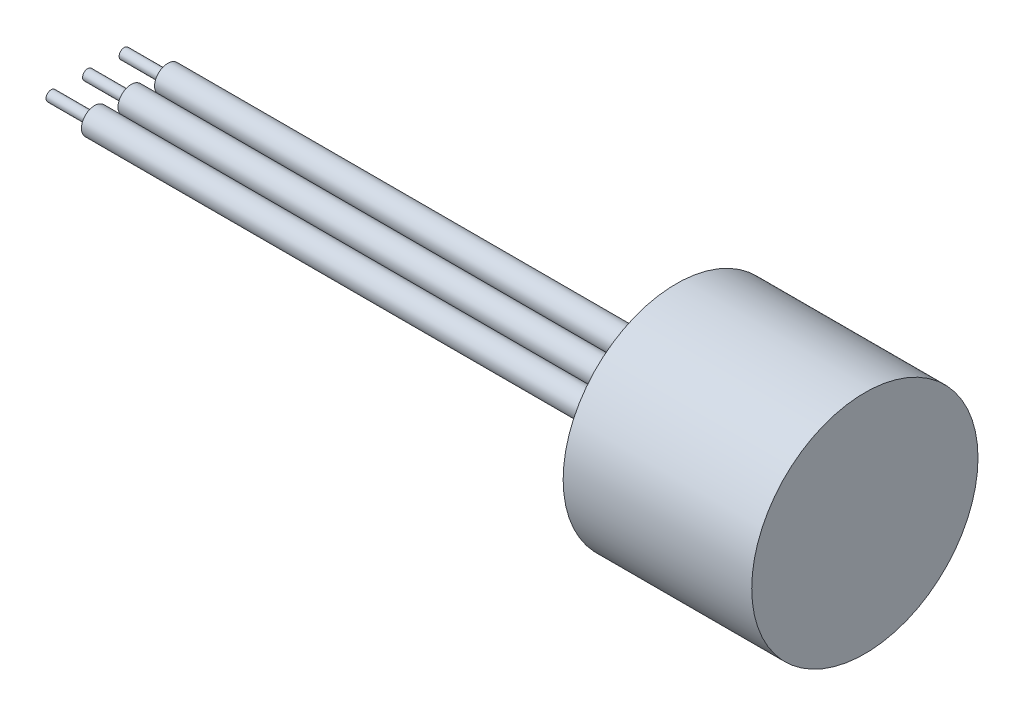
from build123d import *


with BuildPart() as part:
    # Sketch1 → Revolve1 (revolve)
    with BuildSketch(Plane.XY.offset(-0.0942096)):
        Polygon((35.6108, -12.191773113), (35.6108, -5.080397281), (54.6608, -5.080396955), (54.6608, -2.794255147), (39.0398, -2.794245161), (37.5158, -1.270188911), (37.5158, 0.380874088), (58.4708, 0.380865578), (58.4708, -12.191773113), align=None)
    revolve(axis=Axis((58.4708, -12.191773113, -0.0942096), (-1, 0, 0)))

    # Sketch2 → Revolve2 (revolve)
    with BuildSketch(Plane(origin=(0, -12.191772951, 0), x_dir=(1, 0, 0), z_dir=(0, 1, 0))):
        Polygon((-27.8892, -3.9697904), (-27.8892, -3.3982904), (-23.0632, -3.3982904), (-23.0632, -2.509290489), (35.6108, -2.509290489), (35.6108, -3.9697904), align=None)
    revolve(axis=Axis((35.6108, -12.191772951, 3.9697904), (-1, 0, 0)))

    # Sketch3 → Revolve3 (revolve)
    with BuildSketch(Plane(origin=(0, -12.191772951, 0), x_dir=(1, 0, 0), z_dir=(0, 1, 0))):
        Polygon((-27.8892, 4.1582096), (-27.8892, 4.7297096), (-23.0632, 4.7297096), (-23.0632, 5.618709512), (35.6108, 5.618709512), (35.6108, 4.1582096), align=None)
    revolve(axis=Axis((35.6108, -12.191772951, -4.1582096), (-1, 0, 0)))

    # Sketch4 → Revolve4 (revolve)
    with BuildSketch(Plane(origin=(0, -12.191772951, 0), x_dir=(1, 0, 0), z_dir=(0, 1, 0))):
        Polygon((-27.8892, 0.0942096), (-27.8892, 0.6657096), (-23.0632, 0.6657096), (-23.0632, 1.554709511), (35.6108, 1.554709511), (35.6108, 0.0942096), align=None)
    revolve(axis=Axis((35.6108, -12.191772951, -0.0942096), (-1, 0, 0)))


solid = part.part
